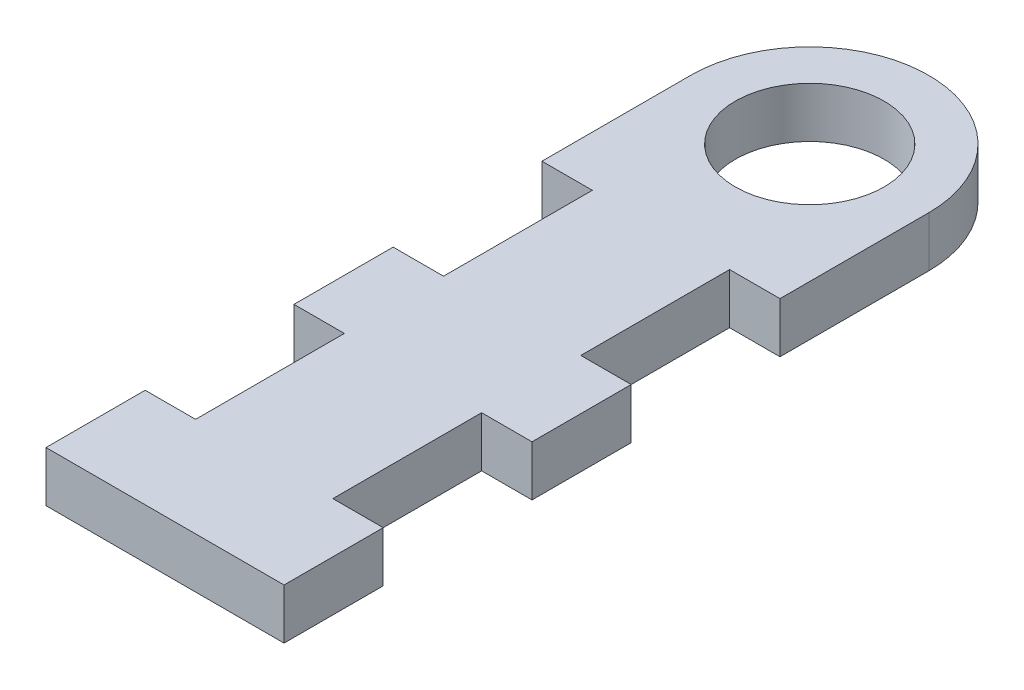
from build123d import *

# Parameters (mm, degrees)
SKETCH1_R           = 7.5
BOSS_EXTRUDE1_DEPTH = 5.08
SKETCH2_W           = 5.08
SKETCH2_H           = 15
CUT_EXTRUDE1_DEPTH  = 5.08


with BuildPart() as part:
    # Sketch1 → Boss-Extrude1 (new body)
    with BuildSketch(Plane(origin=(0, 0, 0), x_dir=(1, 0, 0), z_dir=(0, 1, 0))):
        with BuildLine():
            Line((12, -32.5), (-12, -32.5))
            Line((-12, -32.5), (-12, 32.5))
            ThreePointArc((-12, 32.5), (0, 44.5), (12, 32.5))
            Line((12, 32.5), (12, -32.5))
        make_face()
        with Locations((0, 32.5)):
            Circle(SKETCH1_R, mode=Mode.SUBTRACT)
    extrude(amount=BOSS_EXTRUDE1_DEPTH)

    # Sketch2 → Cut-Extrude1 (cut)
    with BuildSketch(Plane(origin=(0, 5.08, 0), x_dir=(1, 0, 0), z_dir=(0, 1, 0))):
        with Locations((-9.46, -15)):
            Rectangle(SKETCH2_W, SKETCH2_H)
        with Locations((-9.46, 10)):
            Rectangle(SKETCH2_W, SKETCH2_H)
    cut_extrude1 = extrude(amount=-CUT_EXTRUDE1_DEPTH, mode=Mode.SUBTRACT)

    # Mirror2: Cut-Extrude1 across plane
    add(cut_extrude1.mirror(Plane(origin=(0, 0, 0), x_dir=(0, 0, 1), z_dir=(1, 0, 0))), mode=Mode.SUBTRACT)


solid = part.part
